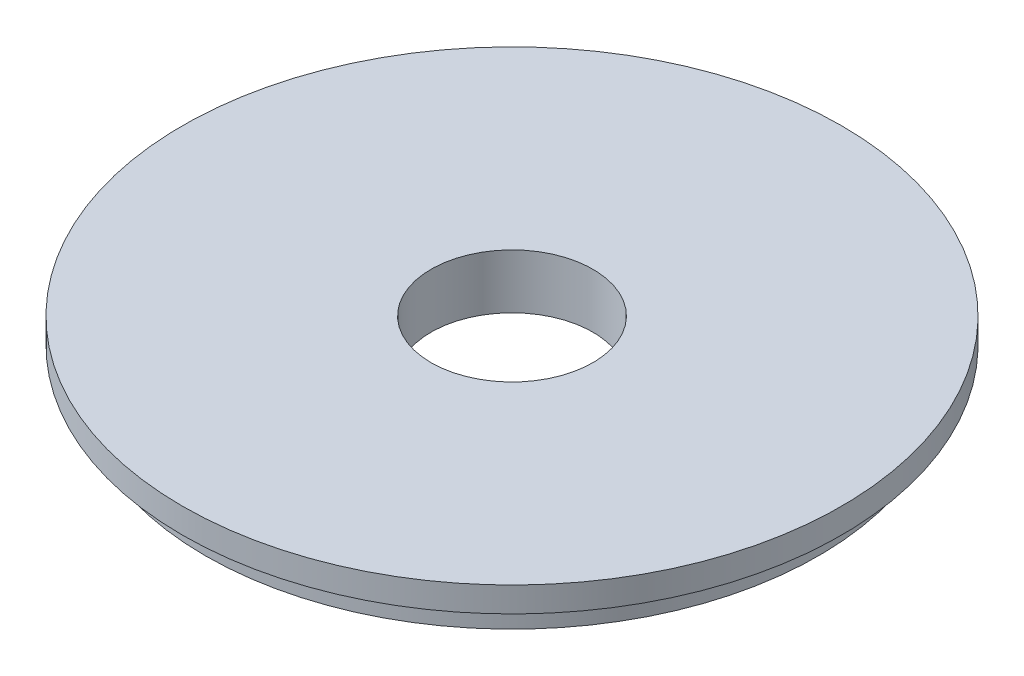
from build123d import *


with BuildPart() as part:
    # Sketch1 → Revolve1 (revolve)
    with BuildSketch(Plane.XY):
        Polygon((-11.3157, 0), (-46.0756, 0), (-46.0756, -3.5052), (-42.8625, -3.5052), (-42.8625, -7.62), (-11.3157, -7.62), align=None)
    revolve(axis=Axis((0, 0, 0), (0, -1, 0)))


solid = part.part
